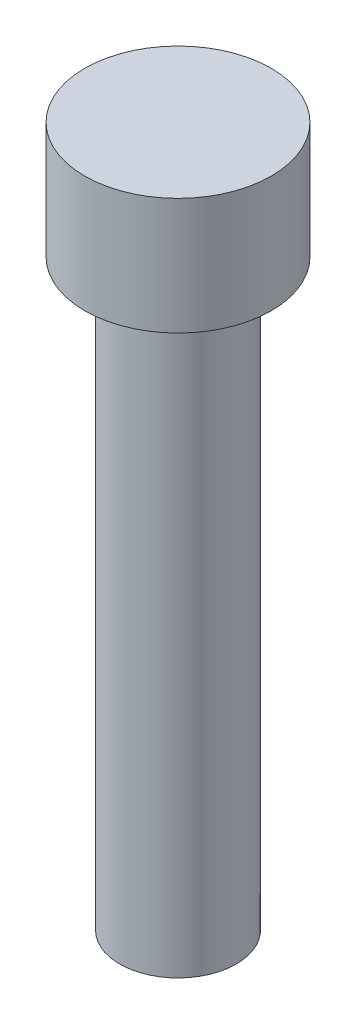
from build123d import *


with BuildPart() as part:
    # Sketch1 → Revolve1 (revolve)
    with BuildSketch(Plane.XY):
        Polygon((0, 0), (0, 30), (4, 30), (4, 25), (2.5, 25), (2.5, 0), align=None)
    revolve(axis=Axis((0, 0, 0), (0, 1, 0)))


solid = part.part
